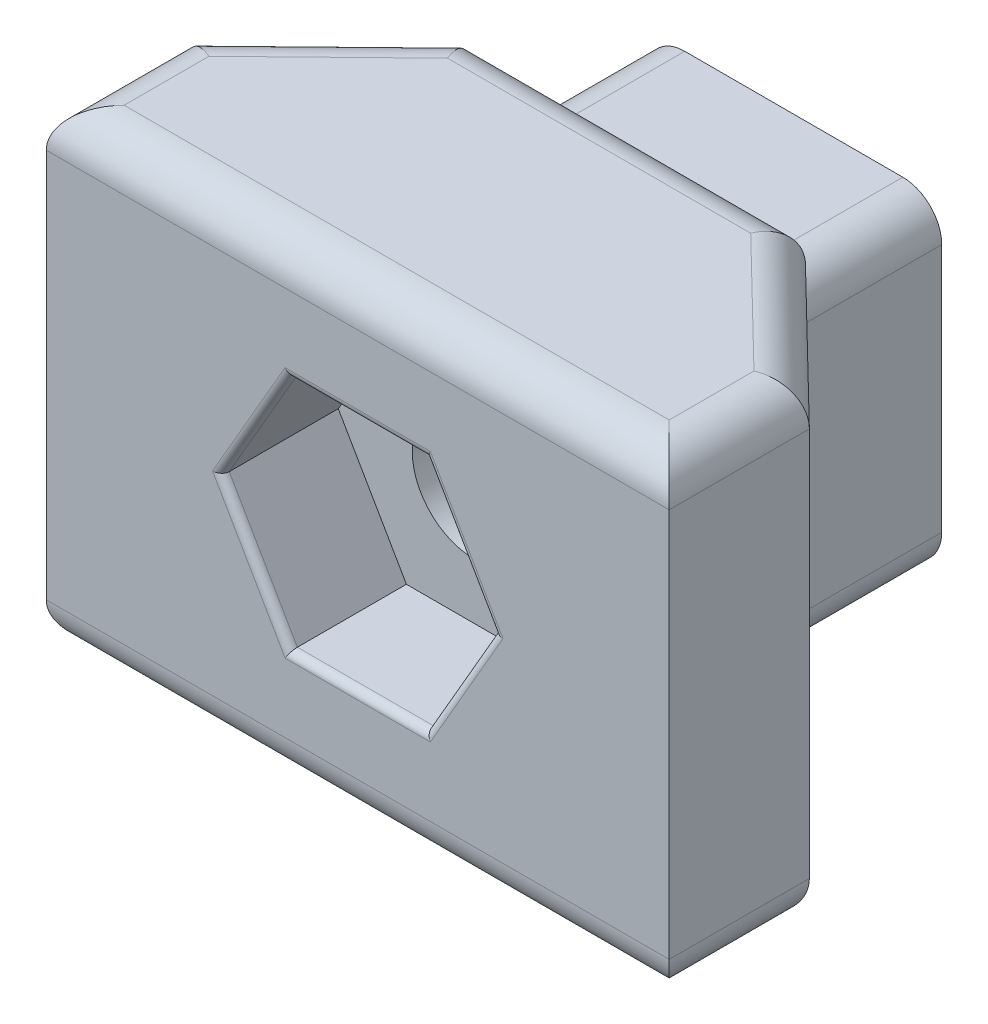
from build123d import *

# Parameters (mm, degrees)
BOSS_EXTRUDE1_DEPTH = 6
SKETCH2_W           = 7.6
SKETCH2_H           = 8.4
BOSS_EXTRUDE2_DEPTH = 4
FILLET1_R           = 1
SKETCH3_R           = 1.6
CUT_EXTRUDE1_DEPTH  = 12.2
FILLET2_R           = 1
CUT_EXTRUDE2_DEPTH  = 3
FILLET3_R           = 0.2


with BuildPart() as part:
    # Sketch1 → Boss-Extrude1 (new body, symmetric)
    with BuildSketch(Plane(origin=(0, 0, 0), x_dir=(1, 0, 0), z_dir=(0, 1, 0))):
        Polygon((-8, 0), (8, 0), (8, 3.6), (4.3, 7.2), (-4.3, 7.2), (-8, 3.6), align=None)
    extrude(amount=BOSS_EXTRUDE1_DEPTH, both=True)

    # Sketch2 → Boss-Extrude2 (add)
    with BuildSketch(Plane(origin=(0, 0, -7.2), x_dir=(-1, 0, 0), z_dir=(0, 0, -1))):
        Rectangle(SKETCH2_W, SKETCH2_H)
    extrude(amount=BOSS_EXTRUDE2_DEPTH)

    # Fillet1
    fillet1_edges = [part.edges().sort_by_distance(p)[0] for p in [
        (-6.15, 6, -5.4),
        (-8, 6, -1.8),
        (0, 6, 0),
        (8, 6, -1.8),
        (6.15, 6, -5.4),
        (8, -6, -1.8),
        (0, -6, 0),
        (-8, -6, -1.8),
        (-6.15, -6, -5.4),
        (0, -6, -7.2),
        (6.15, -6, -5.4),
        (0, 6, -7.2),
    ]]
    fillet(fillet1_edges, radius=FILLET1_R)

    # Sketch3 → Cut-Extrude1 (cut, through all)
    with BuildSketch(Plane(origin=(0, 0, -11.2), x_dir=(-1, 0, 0), z_dir=(0, 0, -1))):
        Circle(SKETCH3_R)
    extrude(amount=-CUT_EXTRUDE1_DEPTH, mode=Mode.SUBTRACT)

    # Fillet2
    fillet2_edges = [part.edges().sort_by_distance(p)[0] for p in [
        (-3.8, -4.2, -9.2),
        (-3.8, 4.2, -9.2),
        (3.8, 4.2, -9.2),
        (3.8, -4.2, -9.2),
    ]]
    fillet(fillet2_edges, radius=FILLET2_R)

    # Sketch4 → Cut-Extrude2 (cut)
    with BuildSketch(Plane.XY):
        Polygon((3.5, 0), (1.75, 3.031088913), (-1.75, 3.031088913), (-3.5, 0), (-1.75, -3.031088913), (1.75, -3.031088913), align=None)
    extrude(amount=-CUT_EXTRUDE2_DEPTH, mode=Mode.SUBTRACT)

    # Fillet3
    fillet3_edges = [part.edges().sort_by_distance(p)[0] for p in [
        (2.625, -1.515544457, 0),
        (2.625, 1.515544457, 0),
        (0, 3.031088913, 0),
        (-2.625, 1.515544457, 0),
        (-2.625, -1.515544457, 0),
        (0, -3.031088913, 0),
    ]]
    fillet(fillet3_edges, radius=FILLET3_R)


solid = part.part
